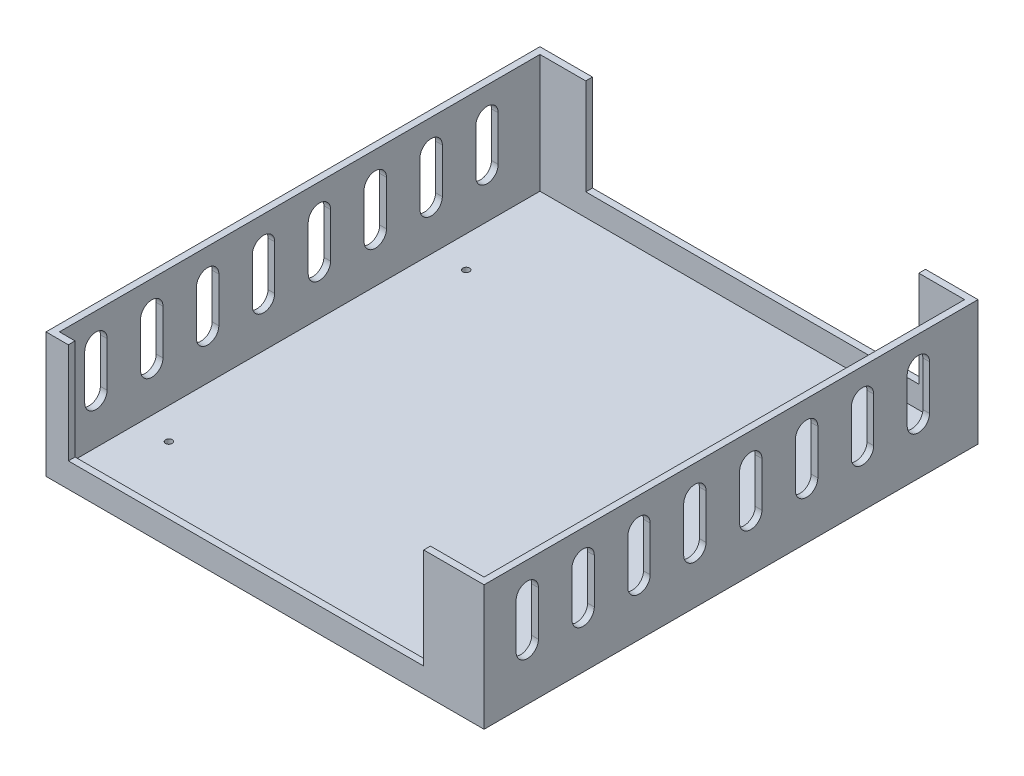
from build123d import *

# Parameters (mm, degrees)
SKETCH_2_W          = 196
SKETCH_2_H          = 221
SKETCH_2_R          = 1.5
EXTRUDE_8_DEPTH     = 3
SKETCH_1_W          = 196
SKETCH_1_H          = 221
SKETCH_1_W_2        = 190
SKETCH_1_H_2        = 215
EXTRUDE_9_DEPTH     = 8
EXTRUDE_10_DEPTH    = 45
CUT_EXTRUDE_1_DEPTH = 5
CUT_EXTRUDE_2_DEPTH = 209


with BuildPart() as part:
    # 草图2 → 凸台-拉伸8 (new body)
    with BuildSketch(Plane(origin=(0, -3, 0), x_dir=(1, 0, 0), z_dir=(0, 1, 0))):
        with Locations((95, 107.5)):
            Rectangle(SKETCH_2_W, SKETCH_2_H)
        with Locations((14, 168)):
            Circle(SKETCH_2_R, mode=Mode.SUBTRACT)
        with Locations((173, 168)):
            Circle(SKETCH_2_R, mode=Mode.SUBTRACT)
        with Locations((173, 11)):
            Circle(SKETCH_2_R, mode=Mode.SUBTRACT)
        with Locations((14, 35)):
            Circle(SKETCH_2_R, mode=Mode.SUBTRACT)
    extrude(amount=EXTRUDE_8_DEPTH)

    # 草图1 → 凸台-拉伸9 (add)
    with BuildSketch(Plane(origin=(0, 0, 0), x_dir=(1, 0, 0), z_dir=(0, 1, 0))):
        with Locations((95, 107.5)):
            Rectangle(SKETCH_1_W, SKETCH_1_H)
        with Locations((95, 107.5)):
            Rectangle(SKETCH_1_W_2, SKETCH_1_H_2, mode=Mode.SUBTRACT)
    extrude(amount=EXTRUDE_9_DEPTH)

    # 草图9 → 凸台-拉伸10 (add)
    with BuildSketch(Plane(origin=(0, 8, 0), x_dir=(1, 0, 0), z_dir=(0, 1, 0))):
        Polygon((166, -3), (193, -3), (193, 218), (-3, 218), (-3, -3), (7, -3), (7, 0), (0, 0), (0, 215), (190, 215), (190, 0), (166, 0), align=None)
    extrude(amount=EXTRUDE_10_DEPTH)

    # 草图10 → 切除-拉伸1 (cut)
    with BuildSketch(Plane(origin=(0, 0, -218), x_dir=(-1, 0, 0), z_dir=(0, 0, -1))):
        Polygon((-95, 10), (-169.5, 10), (-169.5, 53), (-20.5, 53), (-20.5, 10), align=None)
    extrude(amount=-CUT_EXTRUDE_1_DEPTH, mode=Mode.SUBTRACT)

    # 草图11 → 切除-拉伸2 (cut)
    with BuildSketch(Plane(origin=(193, 0, 0), x_dir=(0, 0, -1), z_dir=(1, 0, 0))):
        with BuildLine():
            Line((196.326880945, 39.740756609), (196.326880945, 19.740756609))
            ThreePointArc((196.326880945, 19.740756609), (194.862414851, 16.205222703), (191.326880945, 14.740756609))
            ThreePointArc((191.326880945, 14.740756609), (187.791347039, 16.205222703), (186.326880945, 19.740756609))
            Line((186.326880945, 19.740756609), (186.326880945, 39.740756609))
            ThreePointArc((186.326880945, 39.740756609), (187.791347039, 43.276290515), (191.326880945, 44.740756609))
            ThreePointArc((191.326880945, 44.740756609), (194.862414851, 43.276290515), (196.326880945, 39.740756609))
        make_face()
        with BuildLine():
            Line((36.326880945, 39.740756609), (36.326880945, 19.740756609))
            ThreePointArc((36.326880945, 19.740756609), (37.791347039, 16.205222703), (41.326880945, 14.740756609))
            ThreePointArc((41.326880945, 14.740756609), (44.862414851, 16.205222703), (46.326880945, 19.740756609))
            Line((46.326880945, 19.740756609), (46.326880945, 39.740756609))
            ThreePointArc((46.326880945, 39.740756609), (44.862414851, 43.276290515), (41.326880945, 44.740756609))
            ThreePointArc((41.326880945, 44.740756609), (37.791347039, 43.276290515), (36.326880945, 39.740756609))
        make_face()
        with BuildLine():
            Line((11.326880945, 39.740756609), (11.326880945, 19.740756609))
            ThreePointArc((11.326880945, 19.740756609), (12.791347039, 16.205222703), (16.326880945, 14.740756609))
            ThreePointArc((16.326880945, 14.740756609), (19.862414851, 16.205222703), (21.326880945, 19.740756609))
            Line((21.326880945, 19.740756609), (21.326880945, 39.740756609))
            ThreePointArc((21.326880945, 39.740756609), (19.862414851, 43.276290515), (16.326880945, 44.740756609))
            ThreePointArc((16.326880945, 44.740756609), (12.791347039, 43.276290515), (11.326880945, 39.740756609))
        make_face()
        with BuildLine():
            Line((61.326880945, 39.740756609), (61.326880945, 19.740756609))
            ThreePointArc((61.326880945, 19.740756609), (62.791347039, 16.205222703), (66.326880945, 14.740756609))
            ThreePointArc((66.326880945, 14.740756609), (69.862414851, 16.205222703), (71.326880945, 19.740756609))
            Line((71.326880945, 19.740756609), (71.326880945, 39.740756609))
            ThreePointArc((71.326880945, 39.740756609), (69.862414851, 43.276290515), (66.326880945, 44.740756609))
            ThreePointArc((66.326880945, 44.740756609), (62.791347039, 43.276290515), (61.326880945, 39.740756609))
        make_face()
        with BuildLine():
            Line((86.326880945, 39.740756609), (86.326880945, 19.740756609))
            ThreePointArc((86.326880945, 19.740756609), (87.791347039, 16.205222703), (91.326880945, 14.740756609))
            ThreePointArc((91.326880945, 14.740756609), (94.862414851, 16.205222703), (96.326880945, 19.740756609))
            Line((96.326880945, 19.740756609), (96.326880945, 39.740756609))
            ThreePointArc((96.326880945, 39.740756609), (94.862414851, 43.276290515), (91.326880945, 44.740756609))
            ThreePointArc((91.326880945, 44.740756609), (87.791347039, 43.276290515), (86.326880945, 39.740756609))
        make_face()
        with BuildLine():
            Line((111.326880945, 39.740756609), (111.326880945, 19.740756609))
            ThreePointArc((111.326880945, 19.740756609), (112.791347039, 16.205222703), (116.326880945, 14.740756609))
            ThreePointArc((116.326880945, 14.740756609), (119.862414851, 16.205222703), (121.326880945, 19.740756609))
            Line((121.326880945, 19.740756609), (121.326880945, 39.740756609))
            ThreePointArc((121.326880945, 39.740756609), (119.862414851, 43.276290515), (116.326880945, 44.740756609))
            ThreePointArc((116.326880945, 44.740756609), (112.791347039, 43.276290515), (111.326880945, 39.740756609))
        make_face()
        with BuildLine():
            Line((136.326880945, 39.740756609), (136.326880945, 19.740756609))
            ThreePointArc((136.326880945, 19.740756609), (137.791347039, 16.205222703), (141.326880945, 14.740756609))
            ThreePointArc((141.326880945, 14.740756609), (144.862414851, 16.205222703), (146.326880945, 19.740756609))
            Line((146.326880945, 19.740756609), (146.326880945, 39.740756609))
            ThreePointArc((146.326880945, 39.740756609), (144.862414851, 43.276290515), (141.326880945, 44.740756609))
            ThreePointArc((141.326880945, 44.740756609), (137.791347039, 43.276290515), (136.326880945, 39.740756609))
        make_face()
        with BuildLine():
            Line((161.326880945, 39.740756609), (161.326880945, 19.740756609))
            ThreePointArc((161.326880945, 19.740756609), (162.791347039, 16.205222703), (166.326880945, 14.740756609))
            ThreePointArc((166.326880945, 14.740756609), (169.862414851, 16.205222703), (171.326880945, 19.740756609))
            Line((171.326880945, 19.740756609), (171.326880945, 39.740756609))
            ThreePointArc((171.326880945, 39.740756609), (169.862414851, 43.276290515), (166.326880945, 44.740756609))
            ThreePointArc((166.326880945, 44.740756609), (162.791347039, 43.276290515), (161.326880945, 39.740756609))
        make_face()
    extrude(amount=-CUT_EXTRUDE_2_DEPTH, mode=Mode.SUBTRACT)


solid = part.part
